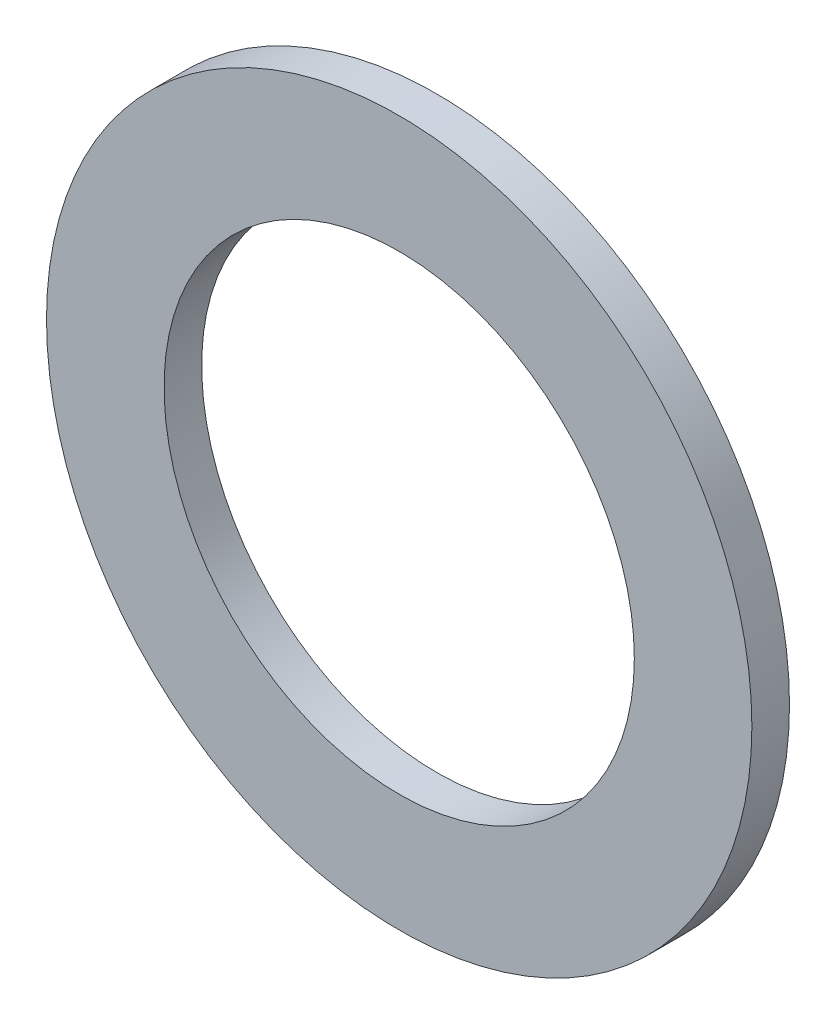
from build123d import *

# Parameters (mm, degrees)
SKETCH1_R           = 2.38125
SKETCH1_R_2         = 1.5875
BOSS_EXTRUDE1_DEPTH = 0.127


with BuildPart() as part:
    # Sketch1 → Boss-Extrude1 (new body, symmetric)
    with BuildSketch(Plane.XY):
        Circle(SKETCH1_R)
        Circle(SKETCH1_R_2, mode=Mode.SUBTRACT)
    extrude(amount=BOSS_EXTRUDE1_DEPTH, both=True)


solid = part.part
